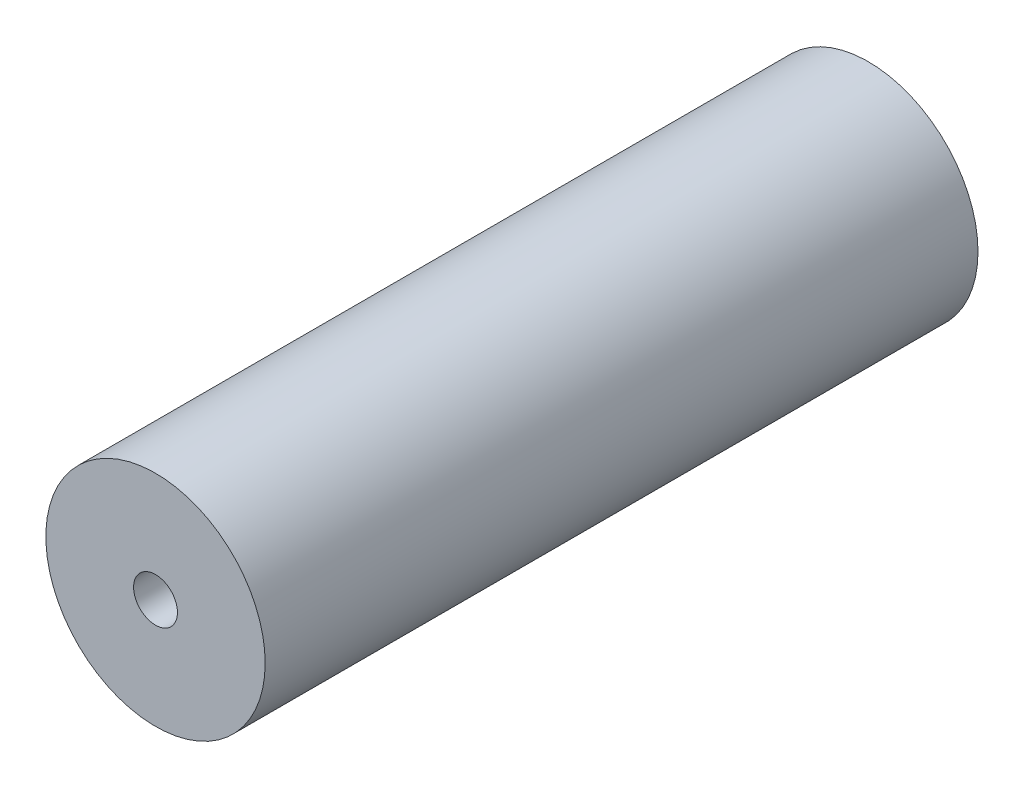
from build123d import *

# Parameters (mm, degrees)
SKETCH1_R           = 10
SKETCH1_R_2         = 2
BOSS_EXTRUDE1_DEPTH = 65


with BuildPart() as part:
    # Sketch1 → Boss-Extrude1 (new body)
    with BuildSketch(Plane.XY):
        Circle(SKETCH1_R)
        Circle(SKETCH1_R_2, mode=Mode.SUBTRACT)
    extrude(amount=BOSS_EXTRUDE1_DEPTH)


solid = part.part
